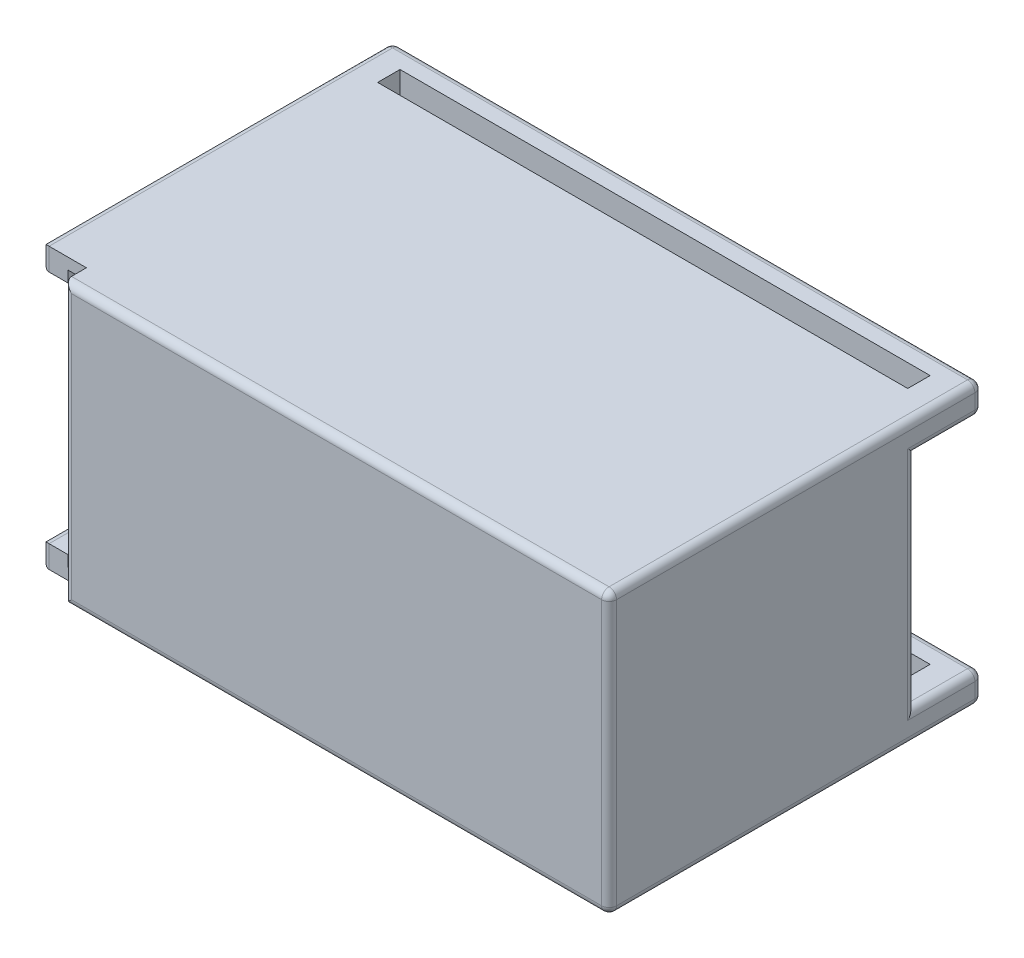
from build123d import *

# Parameters (mm, degrees)
SKETCH1_W           = 79
SKETCH1_H           = 37.5
SKETCH1_R           = 2
BODY_DEPTH          = 5
SKETCH2_W           = 79
SKETCH2_H           = 4
LEG1_DEPTH          = 3
SKETCH3_W           = 4
SKETCH3_H           = 4
LEG2_DEPTH          = 3
SKETCH4_W           = 79
SKETCH4_H           = 4
LEG3_DEPTH          = 3
WALLS_DEPTH         = 33
SKETCH6_W           = 2
SKETCH6_H           = 34.5
CUT_EXTRUDE1_DEPTH  = 17
SKETCH7_W           = 73
SKETCH7_H           = 37.5
BOSS_EXTRUDE1_DEPTH = 3
FILLET1_R           = 1
FILLET2_R           = 1
FILLET3_R           = 1
FILLET4_R           = 1
FILLET6_R           = 1
SKETCH8_W           = 5
SKETCH8_H           = 31.5
BOSS_EXTRUDE2_DEPTH = 16


with BuildPart() as part:
    # Sketch1 → Body (new body)
    with BuildSketch(Plane.XY):
        with Locations((39.5, 18.75)):
            Rectangle(SKETCH1_W, SKETCH1_H)
        with Locations((47, 23.75)):
            Circle(SKETCH1_R, mode=Mode.SUBTRACT)
        with Locations((32, 23.75)):
            Circle(SKETCH1_R, mode=Mode.SUBTRACT)
        with Locations((32, 13.75)):
            Circle(SKETCH1_R, mode=Mode.SUBTRACT)
        with Locations((47, 13.75)):
            Circle(SKETCH1_R, mode=Mode.SUBTRACT)
    extrude(amount=BODY_DEPTH)

    # Sketch2 → Leg1 (add)
    with BuildSketch(Plane(origin=(0, 0, 0), x_dir=(-1, 0, 0), z_dir=(0, 0, -1))):
        with Locations((-39.5, 35.5)):
            Rectangle(SKETCH2_W, SKETCH2_H)
        with Locations((-39.5, 2)):
            Rectangle(SKETCH2_W, SKETCH2_H)
    extrude(amount=LEG1_DEPTH)

    # Sketch3 → Leg2 (add)
    with BuildSketch(Plane(origin=(0, 0, -3), x_dir=(-1, 0, 0), z_dir=(0, 0, -1))):
        with Locations((-77, 35.5)):
            Rectangle(SKETCH3_W, SKETCH3_H)
        with Locations((-2, 35.5)):
            Rectangle(SKETCH3_W, SKETCH3_H)
        with Locations((-2, 2)):
            Rectangle(SKETCH3_W, SKETCH3_H)
        with Locations((-77, 2)):
            Rectangle(SKETCH3_W, SKETCH3_H)
    extrude(amount=LEG2_DEPTH)

    # Sketch4 → Leg3 (add)
    with BuildSketch(Plane(origin=(0, 0, -6), x_dir=(-1, 0, 0), z_dir=(0, 0, -1))):
        with Locations((-39.5, 35.5)):
            Rectangle(SKETCH4_W, SKETCH4_H)
        with Locations((-39.5, 2)):
            Rectangle(SKETCH4_W, SKETCH4_H)
    extrude(amount=LEG3_DEPTH)

    # Sketch5 → Walls (add)
    with BuildSketch(Plane.XY.offset(5)):
        Polygon((0, 37.5), (79, 37.5), (79, 34.5), (79, 29.685442104), (79, 7.814557896), (79, 3), (79, 0), (0, 0), (0, 3), (3, 3), (76, 3), (76, 34.5), (3, 34.5), (0, 34.5), align=None)
    extrude(amount=WALLS_DEPTH)

    # Sketch6 → Cut-Extrude1 (cut)
    with BuildSketch(Plane.XY.offset(38)):
        with Locations((4.5, 18.75)):
            Rectangle(SKETCH6_W, SKETCH6_H)
    extrude(amount=-CUT_EXTRUDE1_DEPTH, mode=Mode.SUBTRACT)

    # Sketch7 → Boss-Extrude1 (add)
    with BuildSketch(Plane.XY.offset(38)):
        with Locations((42.5, 18.75)):
            Rectangle(SKETCH7_W, SKETCH7_H)
    extrude(amount=BOSS_EXTRUDE1_DEPTH)

    # Fillet1
    fillet1_edges = [part.edges().sort_by_distance(p)[0] for p in [
        (39.5, 37.5, -9),
    ]]
    fillet(fillet1_edges, radius=FILLET1_R)

    # Fillet2
    fillet2_edges = [part.edges().sort_by_distance(p)[0] for p in [
        (39.5, 33.5, -9),
    ]]
    fillet(fillet2_edges, radius=FILLET2_R)

    # Fillet3
    fillet3_edges = [part.edges().sort_by_distance(p)[0] for p in [
        (39.5, 0, -9),
    ]]
    fillet(fillet3_edges, radius=FILLET3_R)

    # Fillet4
    fillet4_edges = [part.edges().sort_by_distance(p)[0] for p in [
        (39.5, 4, -9),
    ]]
    fillet(fillet4_edges, radius=FILLET4_R)

    # Fillet6
    fillet6_edges = [part.edges().sort_by_distance(p)[0] for p in [
        (79, 2, -9),
        (79, 3.707106781, -8.707106781),
        (79, 0.292893219, -8.707106781),
        (79, 4, -4),
        (79, 0, 16.5),
        (79, 18.75, 0),
        (79, 18.75, 41),
        (79, 33.5, -4),
        (79, 37.5, 16.5),
        (79, 33.792893219, -8.707106781),
        (79, 37.207106781, -8.707106781),
        (79, 35.5, -9),
        (0, 2, -9),
        (0, 3.707106781, -8.707106781),
        (0, 0.292893219, -8.707106781),
        (0, 4, -4),
        (0, 0, 15),
        (42.5, 0, 41),
        (0, 18.75, 0),
        (42.5, 37.5, 41),
        (6, 18.75, 41),
        (0, 33.5, -4),
        (0, 37.5, 15),
        (0, 33.792893219, -8.707106781),
        (0, 37.207106781, -8.707106781),
        (0, 35.5, -9),
        (0, 1.5, 38),
        (0, 3, 21.5),
        (0, 18.75, 5),
        (0, 34.5, 21.5),
        (0, 36, 38),
    ]]
    fillet(fillet6_edges, radius=FILLET6_R)

    # Sketch8 → Boss-Extrude2 (add)
    with BuildSketch(Plane.ZY.offset(-76)):
        with Locations((30, 18.75)):
            Rectangle(SKETCH8_W, SKETCH8_H)
    extrude(amount=BOSS_EXTRUDE2_DEPTH)


solid = part.part
